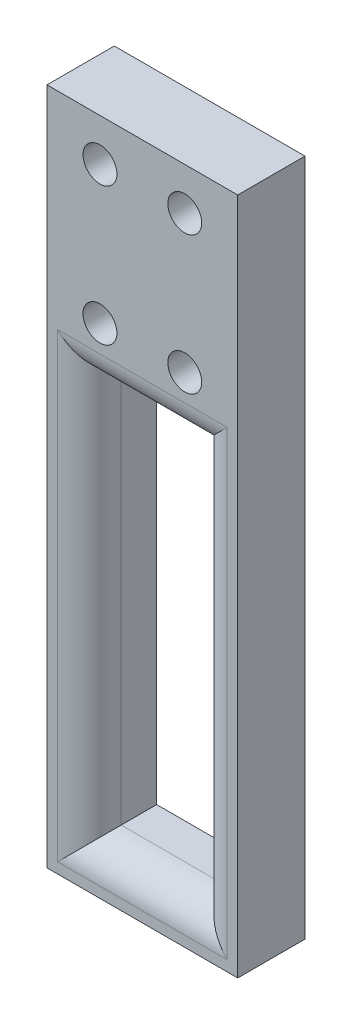
from build123d import *

# Parameters (mm, degrees)
SKETCH1_W                = 18
SKETCH1_H                = 64
BOSS_EXTRUDE1_DEPTH      = 6.35
M3_CLEARANCE_HOLE1_D     = 3.2
M3_CLEARANCE_HOLE1_DEPTH = 7.5
M3_CLEARANCE_HOLE1_TIP   = 0.96137699
SKETCH4_W                = 10
SKETCH4_H                = 37.5
CUT_EXTRUDE1_DEPTH       = 7.35
FILLET1_R                = 3


with BuildPart() as part:
    # Sketch1 → Boss-Extrude1 (new body)
    with BuildSketch(Plane.XY):
        Rectangle(SKETCH1_W, SKETCH1_H)
    extrude(amount=BOSS_EXTRUDE1_DEPTH)

    # M3 Clearance Hole1
    with Locations(Plane(origin=(-4, 15, 6.35), x_dir=(1, 0, 0), z_dir=(0, 0, 1))):
        with Locations((0, 0), (0, 13), (8, 13), (8, 0)):
            Hole(M3_CLEARANCE_HOLE1_D / 2, depth=M3_CLEARANCE_HOLE1_DEPTH)
            with Locations((0, 0, -(M3_CLEARANCE_HOLE1_DEPTH + M3_CLEARANCE_HOLE1_TIP / 2))):  # 118° drill point
                Cone(0, M3_CLEARANCE_HOLE1_D / 2, M3_CLEARANCE_HOLE1_TIP, mode=Mode.SUBTRACT)

    # Sketch4 → Cut-Extrude1 (cut, through all)
    with BuildSketch(Plane.XY.offset(6.35)):
        with Locations((0, -9.25)):
            Rectangle(SKETCH4_W, SKETCH4_H)
    extrude(amount=-CUT_EXTRUDE1_DEPTH, mode=Mode.SUBTRACT)

    # Fillet1
    fillet1_edges = [part.edges().sort_by_distance(p)[0] for p in [
        (5, -9.25, 6.35),
        (0, 9.5, 6.35),
        (-5, -9.25, 6.35),
        (0, -28, 6.35),
    ]]
    fillet(fillet1_edges, radius=FILLET1_R)


solid = part.part
